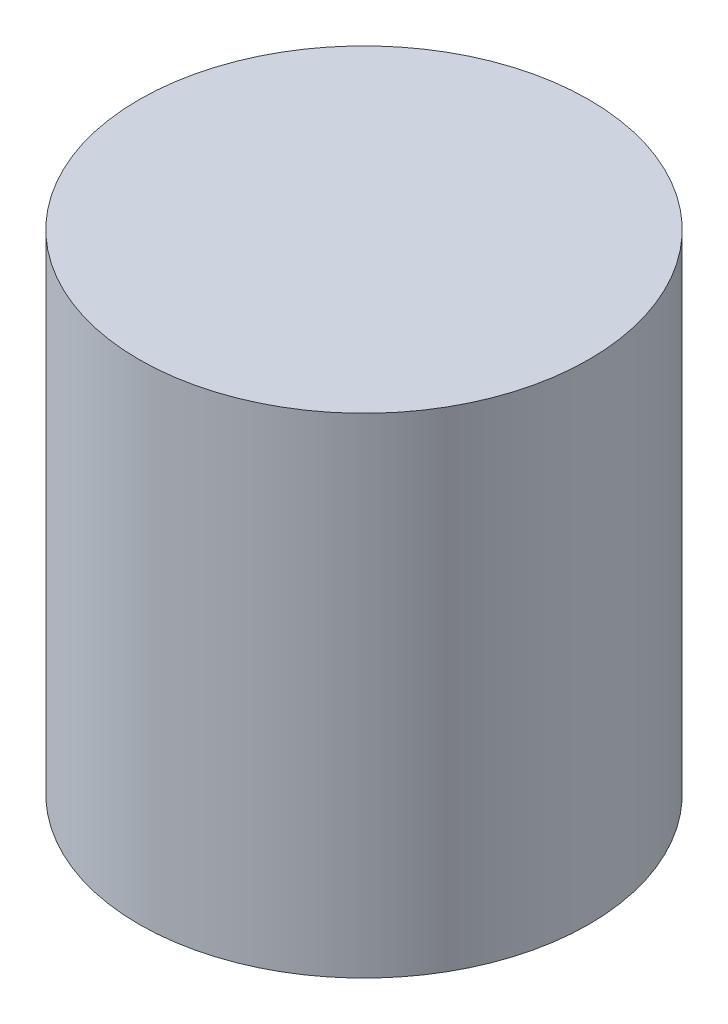
from build123d import *

# Parameters (mm, degrees)
SKETCH1_R           = 2.921
BOSS_EXTRUDE1_DEPTH = 6.35


with BuildPart() as part:
    # Sketch1 → Boss-Extrude1 (new body)
    with BuildSketch(Plane(origin=(0, 13.188860711, 0), x_dir=(1, 0, 0), z_dir=(0, 1, 0))):
        with Locations((153.821054168, 6.35)):
            Circle(SKETCH1_R)
    extrude(amount=BOSS_EXTRUDE1_DEPTH)


solid = part.part
